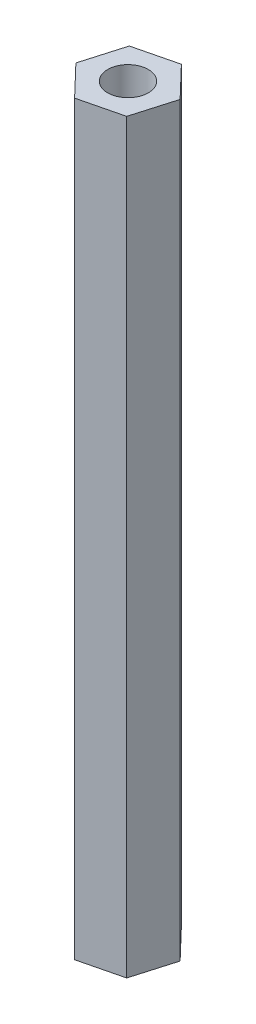
from build123d import *

# Parameters (mm, degrees)
BOSS_EXTRUDE1_DEPTH = 63.5
SKETCH2_R           = 1.7272
CUT_EXTRUDE1_DEPTH  = 9.525
SKETCH3_R           = 1.7272
CUT_EXTRUDE2_DEPTH  = 9.525


with BuildPart() as part:
    # Sketch1 → Boss-Extrude1 (new body)
    with BuildSketch(Plane(origin=(0, 0, 0), x_dir=(1, 0, 0), z_dir=(0, 1, 0))):
        Polygon((-2.767735883, 3.334911674), (-1.744793251, 6.855482892), (-4.282226046, 9.501662807), (-7.842601473, 8.627271504), (-8.865544105, 5.106700285), (-6.32811131, 2.46052037), align=None)
    extrude(amount=BOSS_EXTRUDE1_DEPTH)

    # Sketch2 → Cut-Extrude1 (cut)
    with BuildSketch(Plane(origin=(0, 63.5, 0), x_dir=(1, 0, 0), z_dir=(0, 1, 0))):
        with Locations((-5.305168678, 5.981091589)):
            Circle(SKETCH2_R)
    extrude(amount=-CUT_EXTRUDE1_DEPTH, mode=Mode.SUBTRACT)

    # Sketch3 → Cut-Extrude2 (cut)
    with BuildSketch(Plane.XZ):
        with Locations((-5.305168678, -5.981091589)):
            Circle(SKETCH3_R)
    extrude(amount=-CUT_EXTRUDE2_DEPTH, mode=Mode.SUBTRACT)


solid = part.part
